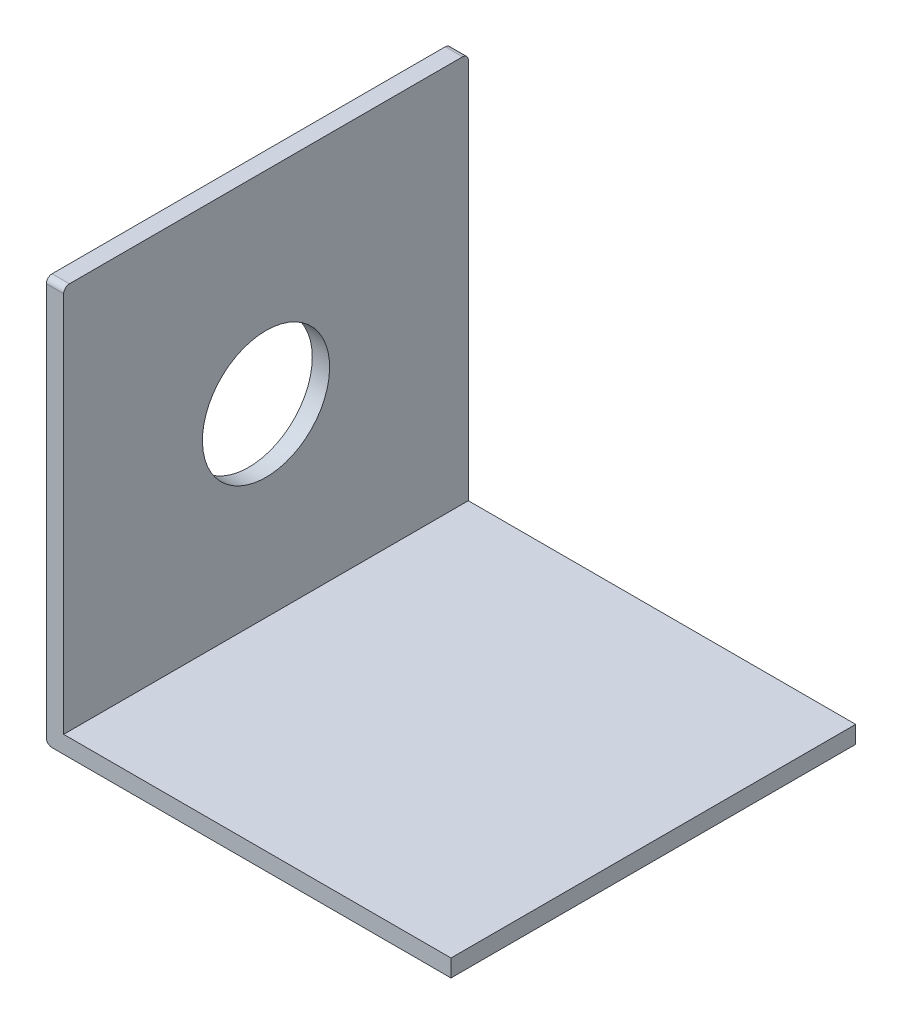
from build123d import *

# Parameters (mm, degrees)
BOSS_EXTRU_1_DEPTH      = 70
ESQUISSE2_R             = 11
ENL_V_MAT_EXTRU_1_DEPTH = 70
CONG_8_R                = 1
CONG_9_R                = 1


with BuildPart() as part:
    # Esquisse1 → Boss.-Extru.1 (new body)
    with BuildSketch(Plane.XY):
        Polygon((0, 0), (70, 0), (70, 3), (3, 3), (3, 70), (0, 70), align=None)
    extrude(amount=BOSS_EXTRU_1_DEPTH)

    # Esquisse2 → Enlèv. mat.-Extru.1 (cut)
    with BuildSketch(Plane(origin=(3, 0, 0), x_dir=(0, 0, -1), z_dir=(1, 0, 0))):
        with Locations(Location((-35, 35, 0), (0, 0, 90))):  # turned: the seam where the file's is
            Circle(ESQUISSE2_R)
    extrude(amount=-ENL_V_MAT_EXTRU_1_DEPTH, mode=Mode.SUBTRACT)

    # Congé8
    cong_8_edges = [part.edges().sort_by_distance(p)[0] for p in [
        (0, 0, 35),
    ]]
    fillet(cong_8_edges, radius=CONG_8_R)

    # Congé9
    cong_9_edges = [part.edges().sort_by_distance(p)[0] for p in [
        (1.5, 70, 70),
        (1.5, 70, 0),
    ]]
    fillet(cong_9_edges, radius=CONG_9_R)


solid = part.part
